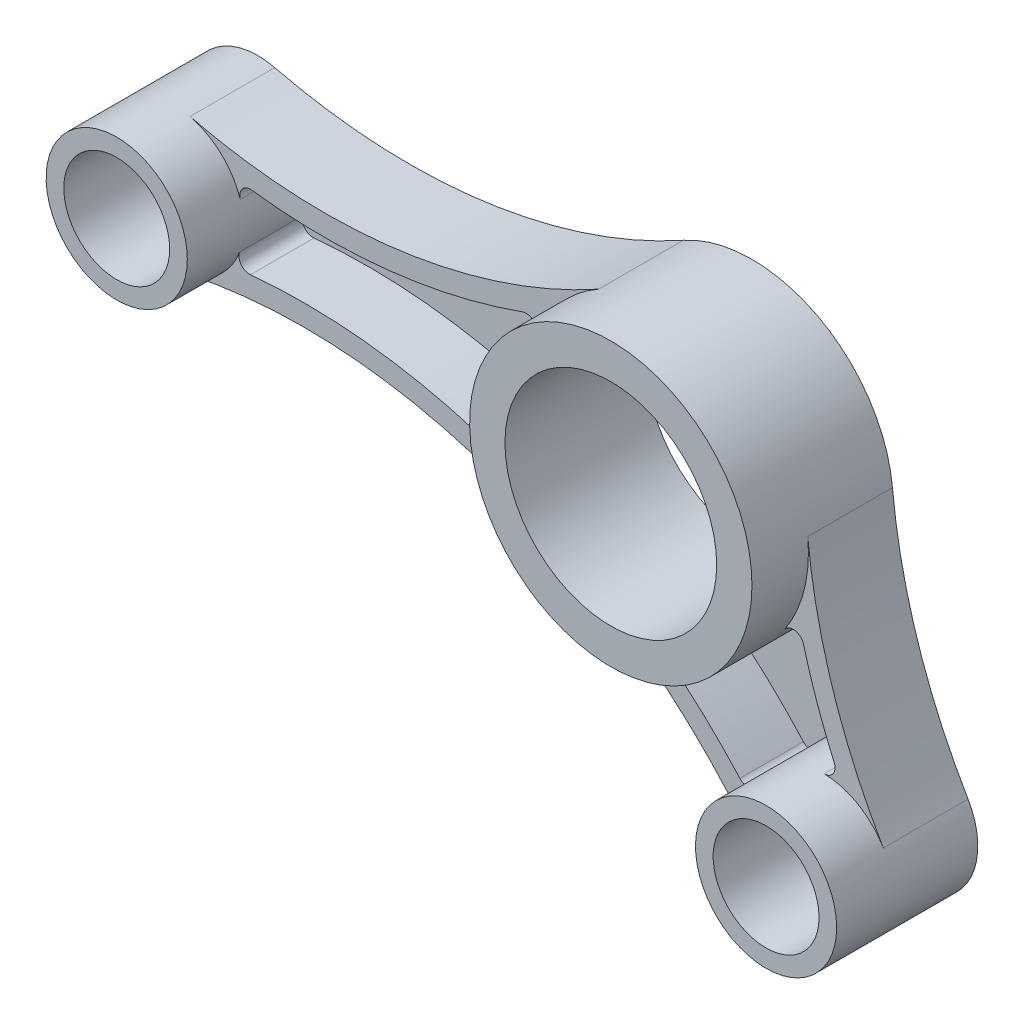
from build123d import *

# Parameters (mm, degrees)
SKETCH1_R           = 20
BOSS_EXTRUDE4_DEPTH = 20
SKETCH1_10_R        = 10
SKETCH1_10_R_2      = 7.5
SKETCH1_10_R_3      = 15
BOSS_EXTRUDE5_DEPTH = 20
SKETCH1_11_R        = 15
CUT_EXTRUDE1_DEPTH  = 20
BOSS_EXTRUDE6_DEPTH = 12
BOSS_EXTRUDE7_DEPTH = 3
FILLET1_R           = 1.5


with BuildPart() as part:
    # Sketch1 → Boss-Extrude4 (new body)
    with BuildSketch(Plane.XY):
        Circle(SKETCH1_R)
    extrude(amount=BOSS_EXTRUDE4_DEPTH)

    # Sketch1_10 → Boss-Extrude5 (add)
    # profile 1 of 3: a face of its own
    with BuildSketch(Plane.XY):
        with Locations((-70, 0)):
            Circle(SKETCH1_10_R)
        with Locations((-70, 0)):
            Circle(SKETCH1_10_R_2, mode=Mode.SUBTRACT)
    # profile 2 of 3: a face of its own
    with BuildSketch(Plane.XY):
        with Locations((22, -36)):
            Circle(SKETCH1_10_R)
        with Locations((22, -36)):
            Circle(SKETCH1_10_R_2, mode=Mode.SUBTRACT)
    # profile 3 of 3: a face of its own
    with BuildSketch(Plane.XY):
        Circle(SKETCH1_10_R_3)
    extrude(amount=BOSS_EXTRUDE5_DEPTH)


with BuildPart() as boss_extrude5_piece_1:
    # of the separate pieces the step leaves, piece 1, a body of its own (boss_extrude5_pieces)
    add(part.part.solids().sort_by_distance((20, 0, 0))[0])

    # Sketch1_11 → Cut-Extrude1 (cut)
    with BuildSketch(Plane.XY):
        Circle(SKETCH1_11_R)
    extrude(amount=CUT_EXTRUDE1_DEPTH, mode=Mode.SUBTRACT)



with BuildPart() as boss_extrude5_piece_2:
    # of the separate pieces the step leaves, piece 2, a body of its own (boss_extrude5_pieces)
    add(part.part.solids().sort_by_distance((32, -36, 0))[0])


with BuildPart() as boss_extrude5_piece_3:
    # of the separate pieces the step leaves, piece 3, a body of its own (boss_extrude5_pieces)
    add(part.part.solids().sort_by_distance((-60, 0, 0))[0])


with BuildPart() as boss_extrude5_piece_1_1:
    add(boss_extrude5_piece_1.part)

    add(boss_extrude5_piece_2.part)  # Boss-Extrude6 merges Boss-Extrude5 piece 2

    add(boss_extrude5_piece_3.part)  # Boss-Extrude6 merges Boss-Extrude5 piece 3
    # Sketch1_12 → Boss-Extrude6 (add)
    with BuildSketch(Plane.XY):
        with BuildLine():
            ThreePointArc((-67.619047619, 9.712418121), (-64.207085766, 8.151205106), (-61.610700763, 5.442394539))
            ThreePointArc((-61.610700763, 5.442394539), (-38.89416694, 4.977846482), (-16.902840155, 10.690836951))
            ThreePointArc((-16.902840155, 10.690836951), (-13.734956085, 14.537915303), (-9.714285714, 17.482352618))
            ThreePointArc((-9.714285714, 17.482352618), (-37.932007586, 8.122402385), (-67.619047619, 9.712418121))
        make_face()
        with BuildLine():
            ThreePointArc((-14.595467543, -13.673782476), (-37.607048321, -6.216745586), (-61.791440547, -5.711352878))
            ThreePointArc((-61.791440547, -5.711352878), (-64.474228629, -8.334617613), (-67.934982867, -9.784462389))
            ThreePointArc((-67.934982867, -9.784462389), (-22.262897918, -13.560739124), (13.842794911, -41.784462389))
            ThreePointArc((13.842794911, -41.784462389), (12.285119236, -38.370884169), (12.095188973, -34.623512255))
            ThreePointArc((12.095188973, -34.623512255), (4.201963756, -26.450336843), (-4.733552286, -19.431764787))
            ThreePointArc((-4.733552286, -19.431764787), (-10.084212511, -17.271614228), (-14.595467543, -13.673782476))
        make_face()
        with BuildLine():
            ThreePointArc((30.614150003, -30.920982406), (23.463789692, -15.074619609), (19.905470006, 1.94223167))
            ThreePointArc((19.905470006, 1.94223167), (19.767704174, -3.039386732), (18.402586233, -7.832293401))
            ThreePointArc((18.402586233, -7.832293401), (21.047204692, -17.304888513), (24.793712928, -26.398168504))
            ThreePointArc((24.793712928, -26.398168504), (28.135861436, -28.103722115), (30.614150003, -30.920982406))
        make_face()
    extrude(amount=BOSS_EXTRUDE6_DEPTH)

    # Sketch1_13 → Boss-Extrude7 (add)
    with BuildSketch(Plane.XY):
        with BuildLine():
            ThreePointArc((-61.610700763, 5.442394539), (-60.001312654, -0.162022728), (-61.791440547, -5.711352878))
            ThreePointArc((-61.791440547, -5.711352878), (-37.607048321, -6.216745586), (-14.595467543, -13.673782476))
            ThreePointArc((-14.595467543, -13.673782476), (-19.910914517, -1.885598869), (-16.902840155, 10.690836951))
            ThreePointArc((-16.902840155, 10.690836951), (-38.89416694, 4.977846482), (-61.610700763, 5.442394539))
        make_face()
        with BuildLine():
            ThreePointArc((18.402586233, -7.832293401), (8.963679846, -17.878826685), (-4.733552286, -19.431764787))
            ThreePointArc((-4.733552286, -19.431764787), (4.201963756, -26.450336843), (12.095188973, -34.623512255))
            ThreePointArc((12.095188973, -34.623512255), (16.563457073, -27.606907543), (24.793712928, -26.398168504))
            ThreePointArc((24.793712928, -26.398168504), (21.047204692, -17.304888513), (18.402586233, -7.832293401))
        make_face()
    extrude(amount=BOSS_EXTRUDE7_DEPTH)

    # Fillet1
    fillet1_edges = [boss_extrude5_piece_1_1.edges().sort_by_distance(p)[0] for p in [
        (12.095188973, -34.623512255, 7.5),
        (24.793712928, -26.398168504, 7.5),
        (-4.733552286, -19.431764787, 7.5),
        (18.402586233, -7.832293401, 7.5),
        (-14.595467543, -13.673782476, 7.5),
        (-16.902840155, 10.690836951, 7.5),
        (-61.791440547, -5.711352878, 7.5),
        (-61.610700763, 5.442394539, 7.5),
    ]]
    fillet(fillet1_edges, radius=FILLET1_R)


solid = boss_extrude5_piece_1_1.part
